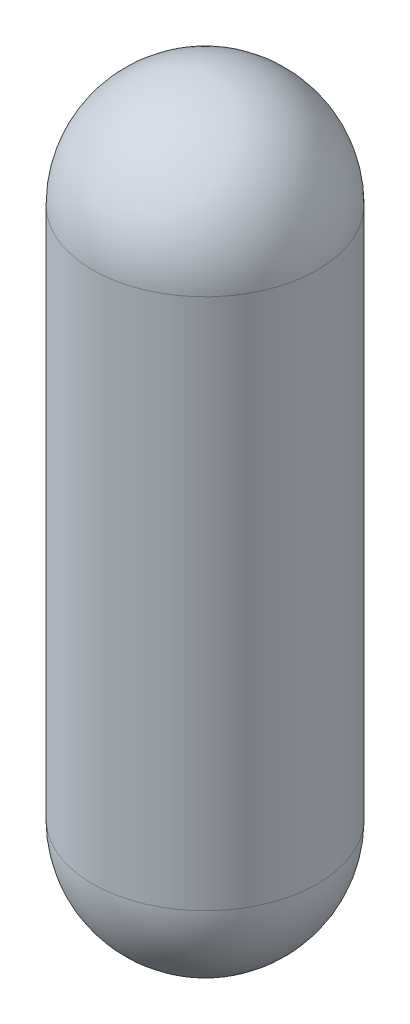
from build123d import *


with BuildPart() as part:
    # Sketch1 → Revolve1 (revolve)
    with BuildSketch(Plane.XY):
        with BuildLine():
            Line((0, 1083.518312986), (0, 1737.568312986))
            ThreePointArc((0, 1737.568312986), (462.483190235, 1546.001503221), (654.05, 1083.518312986))
            Line((654.05, 1083.518312986), (654.05, -2008.381687014))
            ThreePointArc((654.05, -2008.381687014), (462.483190235, -2470.864877249), (0, -2662.431687014))
            Line((0, -2662.431687014), (0, -2008.381687014))
            Line((0, -2008.381687014), (0, 1083.518312986))
        make_face()
    revolve(axis=Axis((0, -2008.381687014, 0), (0, 1, 0)))


solid = part.part
